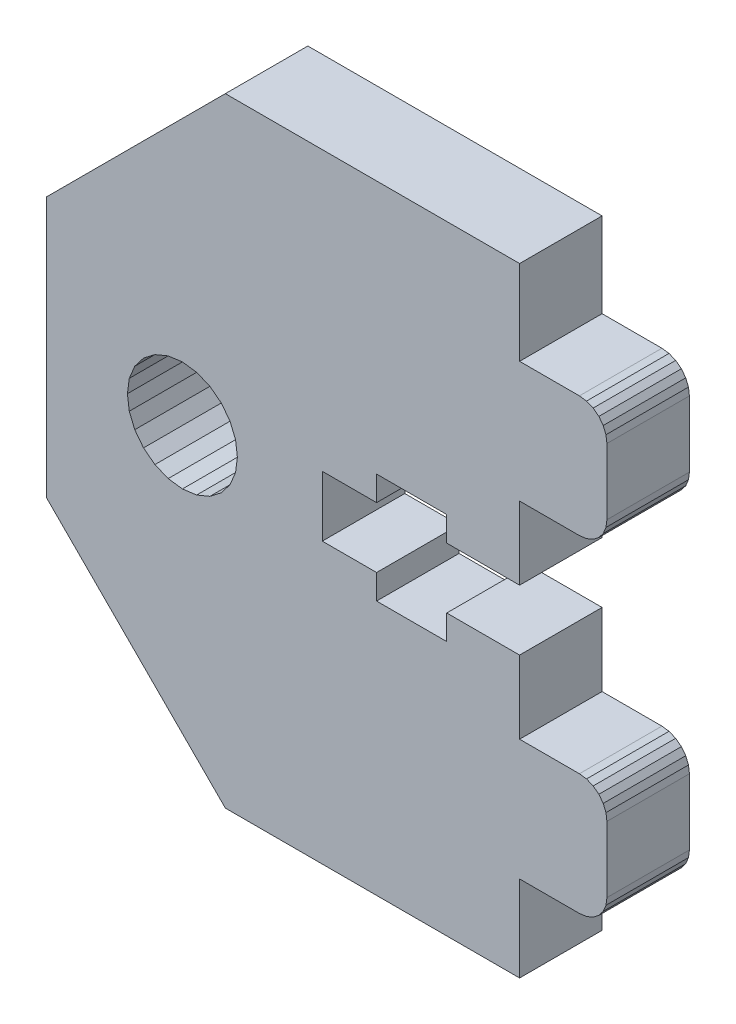
from build123d import *

# Parameters (mm, degrees)
BOSS_EXTRUDE1_DEPTH = 6


with BuildPart() as part:
    # Sketch1 → Boss-Extrude1 (new body)
    with BuildSketch(Plane.XY):
        Polygon((57.521474666, -355.462944523), (44.521477546, -368.462941643), (44.521477546, -387.422916834), (57.521474666, -400.462926923), (78.921469418, -400.462926923), (78.921469418, -394.222907142), (83.271467309, -394.222907142), (83.7891054, -394.154758794), (84.271467309, -393.954957949), (84.685680872, -393.637120704), (85.003518117, -393.222907142), (85.203318962, -392.740545232), (85.271467309, -392.222907142), (85.271467309, -387.422911176), (85.203318962, -386.905273086), (85.003518117, -386.422911176), (84.685680872, -386.008697614), (84.271467309, -385.690860369), (83.7891054, -385.491059524), (83.271467309, -385.422911176), (78.921469418, -385.422911176), (78.921469418, -380.12291917), (73.621470596, -380.12291917), (73.621470596, -381.922917402), (68.521472832, -381.922917402), (68.521472832, -380.12291917), (64.57147301, -380.12291917), (64.57147301, -375.722914498), (68.521472832, -375.722914498), (68.521472832, -373.922916266), (73.621470596, -373.922916266), (73.621470596, -375.722914498), (78.921469418, -375.722914498), (78.921469418, -370.422917243), (83.271467309, -370.422917243), (83.7891054, -370.354768896), (84.271467309, -370.154968051), (84.685680872, -369.837130805), (85.003518117, -369.422917243), (85.203318962, -368.940555333), (85.271467309, -368.422917243), (85.271467309, -363.622922801), (85.203318962, -363.105284711), (85.003518117, -362.622922801), (84.685680872, -362.208709239), (84.271467309, -361.890871993), (83.7891054, -361.691071148), (83.271467309, -361.622922801), (78.921469418, -361.622922801), (78.921469418, -355.462944523), align=None)
        Polygon((50.398749784, -377.922916834), (50.535046479, -378.958193014), (50.934648169, -379.922916834), (51.57032266, -380.751343959), (52.398749784, -381.387018449), (53.363473604, -381.786620139), (54.398749784, -381.922916834), (55.434025965, -381.786620139), (56.398749784, -381.387018449), (57.227176909, -380.751343959), (57.862851399, -379.922916834), (58.262453089, -378.958193014), (58.398749784, -377.922916834), (58.262453089, -376.887640653), (57.862851399, -375.922916834), (57.227176909, -375.094489709), (56.398749784, -374.458815219), (55.434025965, -374.059213529), (54.398749784, -373.922916834), (53.363473604, -374.059213529), (52.398749784, -374.458815219), (51.57032266, -375.094489709), (50.934648169, -375.922916834), (50.535046479, -376.887640653), align=None, mode=Mode.SUBTRACT)
    extrude(amount=BOSS_EXTRUDE1_DEPTH)


solid = part.part
